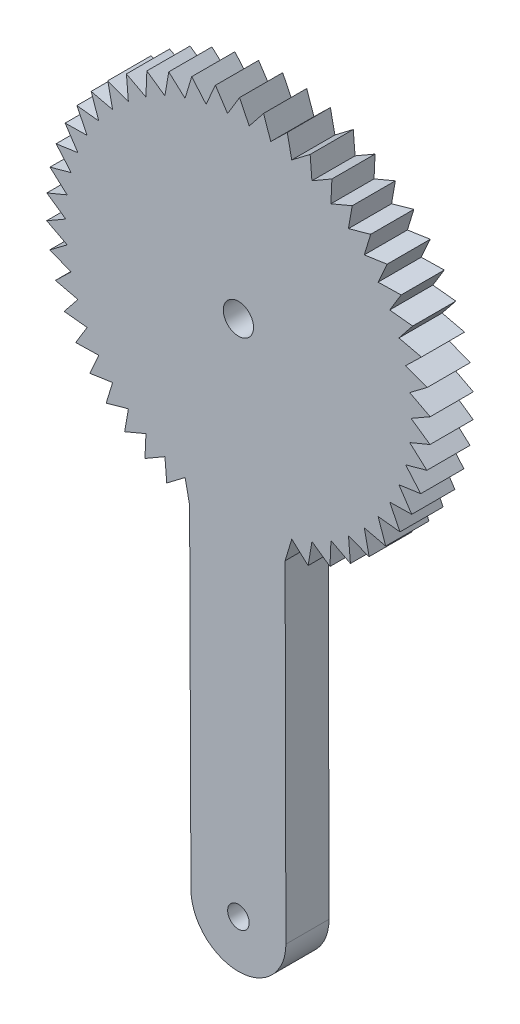
from build123d import *

# Parameters (mm, degrees)
SKETCH1_R           = 1.25
SKETCH1_R_2         = 1.75
BOSS_EXTRUDE2_DEPTH = 5


with BuildPart() as part:
    # Sketch1 → Boss-Extrude2 (new body)
    with BuildSketch(Plane.XY):
        with BuildLine():
            Line((386.419721239, 336.571497364), (385.293365012, 338.860526411))
            Line((385.293365012, 338.860526411), (383.908113185, 336.571143013))
            Line((383.908113185, 336.571143013), (382.503747201, 338.700952515))
            Line((382.503747201, 338.700952515), (381.416354322, 336.256003497))
            Line((381.416354322, 336.256003497), (379.756126272, 338.193005085))
            Line((379.756126272, 338.193005085), (378.983741177, 335.631048754))
            Line((378.983741177, 335.631048754), (377.093833849, 337.344694757))
            Line((377.093833849, 337.344694757), (376.648637512, 334.706134696))
            Line((376.648637512, 334.706134696), (374.558855873, 336.169399891))
            Line((374.558855873, 336.169399891), (374.447869306, 333.495847767))
            Line((374.447869306, 333.495847767), (372.191170461, 334.685655589))
            Line((372.191170461, 334.685655589), (372.41614399, 332.019274917))
            Line((372.41614399, 332.019274917), (370.028117427, 332.916861386))
            Line((370.028117427, 332.916861386), (370.585503084, 330.299702582))
            Line((370.585503084, 330.299702582), (368.10380941, 330.890912222))
            Line((368.10380941, 330.890912222), (368.98481689, 328.364249444))
            Line((368.98481689, 328.364249444), (366.448593896, 328.639758526))
            Line((366.448593896, 328.639758526), (367.639329184, 326.243438755))
            Line((367.639329184, 326.243438755), (365.088574622, 326.198902337))
            Line((365.088574622, 326.198902337), (366.570259113, 323.970716967))
            Line((366.570259113, 323.970716967), (364.045199905, 323.606837414))
            Line((364.045199905, 323.606837414), (365.794466549, 321.58192626))
            Line((365.794466549, 321.58192626), (363.334924388, 320.904442171))
            Line((363.334924388, 320.904442171), (365.324186205, 319.114739291))
            Line((365.324186205, 319.114739291), (362.96894954, 318.134334994))
            Line((362.96894954, 318.134334994), (365.166834682, 316.608065071))
            Line((365.166834682, 316.608065071), (362.953047003, 315.340202129))
            Line((362.953047003, 315.340202129), (365.324893508, 314.101435352))
            Line((365.324893508, 314.101435352), (363.287467569, 312.566108719))
            Line((363.287467569, 312.566108719), (365.795870002, 311.63438118))
            Line((365.795870002, 311.63438118), (363.966937226, 309.855803875))
            Line((363.966937226, 309.855803875), (366.572336582, 309.245809474))
            Line((366.572336582, 309.245809474), (364.980740332, 307.252030724))
            Line((364.980740332, 307.252030724), (367.642047906, 306.973389437))
            Line((367.642047906, 306.973389437), (366.312888606, 304.795852323))
            Line((366.312888606, 304.795852323), (368.988133989, 304.85295849))
            Line((368.988133989, 304.85295849), (367.942373274, 302.526004073))
            Line((367.942373274, 302.526004073), (370.589366248, 302.917957095))
            Line((370.589366248, 302.917957095), (369.84349639, 300.478282837))
            Line((369.84349639, 300.478282837), (372.420492294, 301.198901382))
            Line((372.420492294, 301.198901382), (371.986276106, 298.684982403))
            Line((371.986276106, 298.684982403), (374.452634175, 299.722901884))
            Line((374.452634175, 299.722901884), (374.336919507, 297.174384188))
            Line((374.336919507, 297.174384188), (376.653743801, 298.513235996))
            Line((376.653743801, 298.513235996), (376.85835554, 295.97031123))
            Line((376.85835554, 295.97031123), (378.989108357, 297.588980872))
            Line((378.989108357, 297.588980872), (379.510819655, 295.091752478))
            Line((379.510819655, 295.091752478), (379.666733337, 256.610886765))
            ThreePointArc((379.666733337, 256.610886765), (385.166733337, 251.110886765), (390.666733337, 256.610886765))
            Line((390.666733337, 256.610886765), (390.66667378, 256.636482058))
            Line((390.66667378, 256.636482058), (390.577340402, 295.028768444))
            Line((390.577340402, 295.028768444), (391.349725497, 297.590724775))
            Line((391.349725497, 297.590724775), (393.239632825, 295.877078772))
            Line((393.239632825, 295.877078772), (393.684829162, 298.515638833))
            Line((393.684829162, 298.515638833), (395.774610801, 297.052373638))
            Line((395.774610801, 297.052373638), (395.885597368, 299.725925762))
            Line((395.885597368, 299.725925762), (398.142296213, 298.53611794))
            Line((398.142296213, 298.53611794), (397.917322684, 301.202498612))
            Line((397.917322684, 301.202498612), (400.305349247, 300.304912143))
            Line((400.305349247, 300.304912143), (399.74796359, 302.922070947))
            Line((399.74796359, 302.922070947), (402.229657264, 302.330861307))
            Line((402.229657264, 302.330861307), (401.348649784, 304.857524085))
            Line((401.348649784, 304.857524085), (403.884872779, 304.582015003))
            Line((403.884872779, 304.582015003), (402.69413749, 306.978334774))
            Line((402.69413749, 306.978334774), (405.244892052, 307.022871192))
            Line((405.244892052, 307.022871192), (403.763207561, 309.251056562))
            Line((403.763207561, 309.251056562), (406.288266769, 309.614936115))
            Line((406.288266769, 309.614936115), (404.539000125, 311.639847269))
            Line((404.539000125, 311.639847269), (406.998542286, 312.317331358))
            Line((406.998542286, 312.317331358), (405.009280469, 314.107034238))
            Line((405.009280469, 314.107034238), (407.364517134, 315.087438535))
            Line((407.364517134, 315.087438535), (405.166631992, 316.613708458))
            Line((405.166631992, 316.613708458), (407.380419671, 317.8815714))
            Line((407.380419671, 317.8815714), (405.008573166, 319.120338177))
            Line((405.008573166, 319.120338177), (407.045999105, 320.65566481))
            Line((407.045999105, 320.65566481), (404.537596672, 321.587392349))
            Line((404.537596672, 321.587392349), (406.366529448, 323.365969654))
            Line((406.366529448, 323.365969654), (403.761130092, 323.975964055))
            Line((403.761130092, 323.975964055), (405.352726342, 325.969742805))
            Line((405.352726342, 325.969742805), (402.691418768, 326.248384092))
            Line((402.691418768, 326.248384092), (404.020578068, 328.425921206))
            Line((404.020578068, 328.425921206), (401.345332685, 328.368815039))
            Line((401.345332685, 328.368815039), (402.3910934, 330.695769456))
            Line((402.3910934, 330.695769456), (399.744100426, 330.303816434))
            Line((399.744100426, 330.303816434), (400.489970284, 332.743490692))
            Line((400.489970284, 332.743490692), (397.91297438, 332.022872147))
            Line((397.91297438, 332.022872147), (398.347190568, 334.536791126))
            Line((398.347190568, 334.536791126), (395.880832499, 333.498871645))
            Line((395.880832499, 333.498871645), (395.996547167, 336.047389341))
            Line((395.996547167, 336.047389341), (393.679722873, 334.708537533))
            Line((393.679722873, 334.708537533), (393.475111134, 337.251462299))
            Line((393.475111134, 337.251462299), (391.344358317, 335.632792657))
            Line((391.344358317, 335.632792657), (390.822647019, 338.130021051))
            Line((390.822647019, 338.130021051), (388.911568925, 336.257060962))
            Line((388.911568925, 336.257060962), (388.080985766, 338.6692102))
            Line((388.080985766, 338.6692102), (386.419721239, 336.571497364))
        make_face()
        with Locations((385.166733337, 256.610886765)):
            Circle(SKETCH1_R, mode=Mode.SUBTRACT)
        with Locations((385.166733337, 316.610886765)):
            Circle(SKETCH1_R_2, mode=Mode.SUBTRACT)
    extrude(amount=BOSS_EXTRUDE2_DEPTH)


solid = part.part
